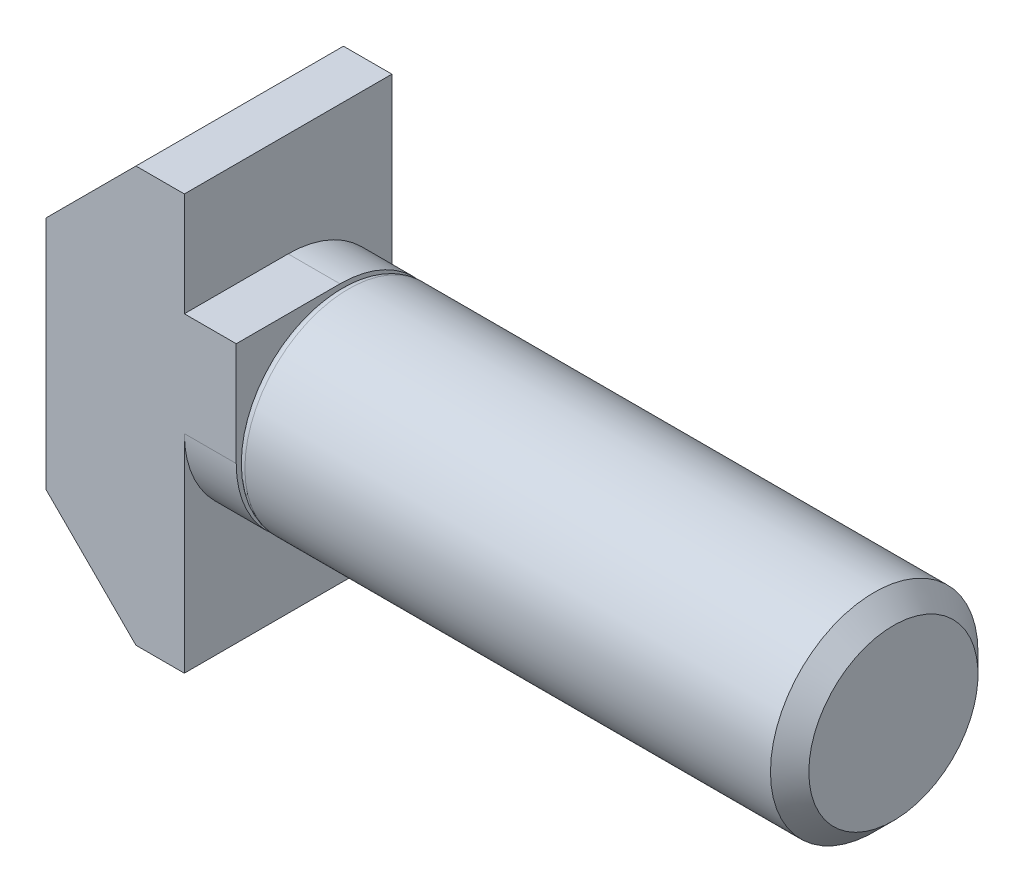
from build123d import *

# Parameters (mm, degrees)
FILLET1_R           = 0.25
BOSS_EXTRUDE1_DEPTH = 3
FILLET2_R           = 3


with BuildPart() as part:
    # BodySke → Base-Revolve (revolve)
    with BuildSketch(Plane.XY):
        Polygon((0, 0), (0, 3), (15.4455, 3), (16, 2.4455), (16, 0), align=None)
    revolve(axis=Axis((-31.75, 0, 0), (1, 0, 0)))

    # Fillet1
    fillet1_edges = [part.edges().sort_by_distance(p)[0] for p in [
        (0, -3, 0),
    ]]
    fillet(fillet1_edges, radius=FILLET1_R)

    # Sketch1 → Boss-Extrude1 (add, symmetric)
    with BuildSketch(Plane.XY):
        Polygon((-5.5, -3.4), (-5.5, 3.4), (-2.9, 6), (-1.5, 6), (-1.5, 3), (0, 3), (0, -3), (-1.5, -3), (-1.5, -6), (-2.9, -6), align=None)
    extrude(amount=BOSS_EXTRUDE1_DEPTH, both=True)

    # Fillet2
    fillet2_edges = [part.edges().sort_by_distance(p)[0] for p in [
        (-0.75, 3, -3),
        (-0.75, -3, 3),
    ]]
    fillet(fillet2_edges, radius=FILLET2_R)


solid = part.part
